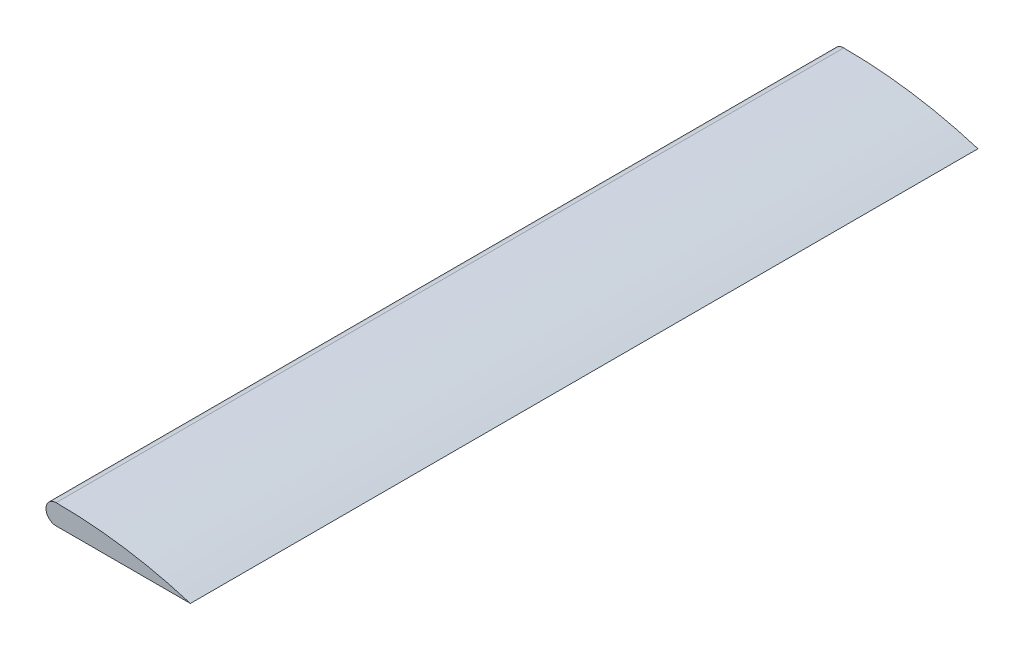
from build123d import *

# Parameters (mm, degrees)
BOSS_EXTRUDE1_DEPTH = 1200


with BuildPart() as part:
    # Sketch1 → Boss-Extrude1 (new body)
    with BuildSketch(Plane.XY):
        with BuildLine():
            Line((0, 0), (204.626828946, 0))
            ThreePointArc((204.626828946, 0), (103.46192135, 23.016854955), (0, 30.746342107))
            ThreePointArc((0, 30.746342107), (-15.373171054, 15.373171054), (0, 0))
        make_face()
    extrude(amount=BOSS_EXTRUDE1_DEPTH)


solid = part.part
